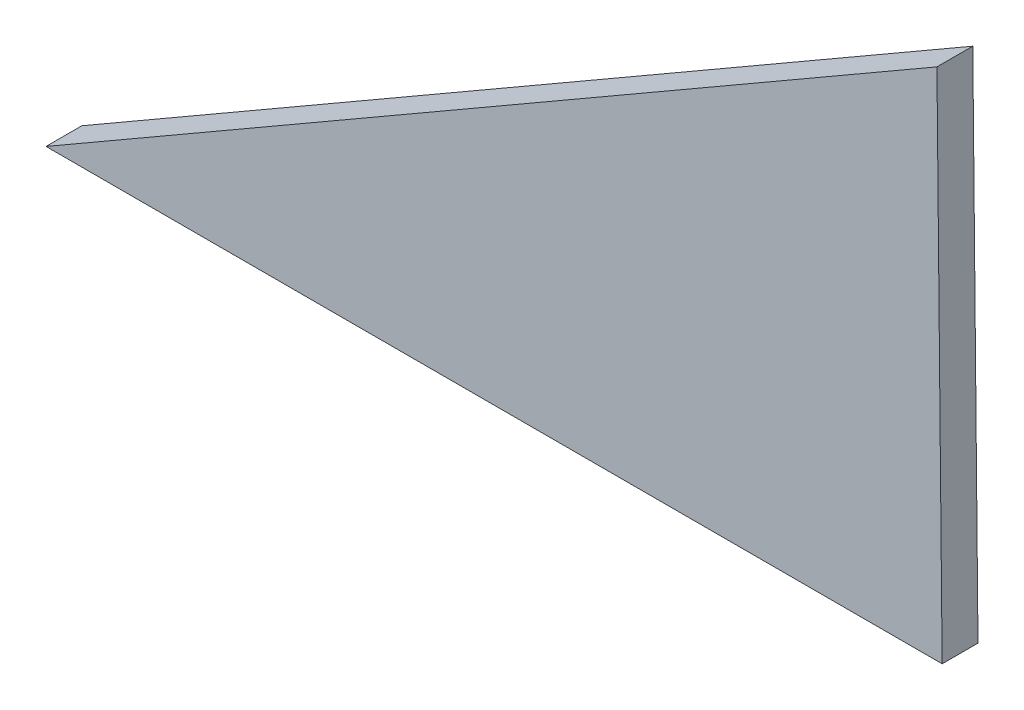
from build123d import *

# Parameters (mm, degrees)
BOSS_EXTRUDE1_DEPTH = 4


with BuildPart() as part:
    # Sketch1 → Boss-Extrude1 (new body)
    with BuildSketch(Plane.XY):
        Polygon((-46.572608973, -38.819952787), (53.427391027, -38.819952787), (52.84563857, 18.579199194), align=None)
    extrude(amount=BOSS_EXTRUDE1_DEPTH)


solid = part.part
